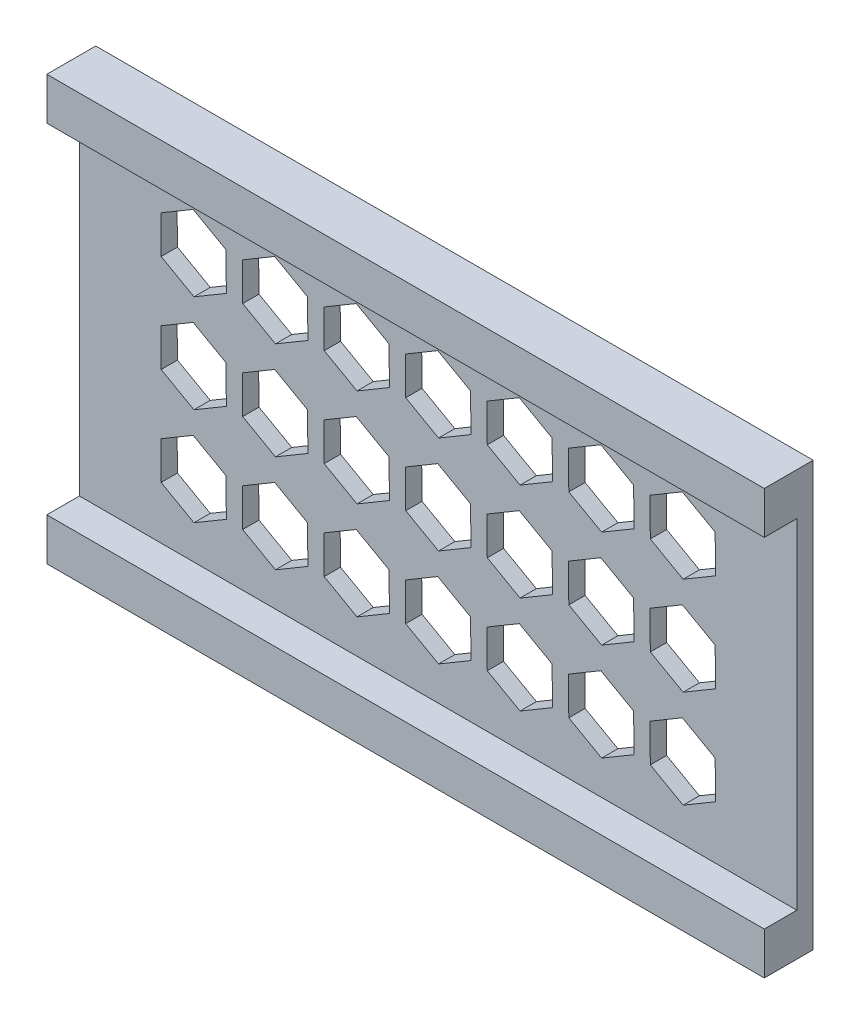
from build123d import *

# Parameters (mm, degrees)
SKETCH_3_W          = 220
SKETCH_3_H          = 130
EXTRUDE_1_DEPTH     = 5
CUT_EXTRUDE_1_DEPTH = 128.867118525
SKETCH_3_4_W        = 220
SKETCH_3_4_H        = 13
EXTRUDE_2_DEPTH     = 15


with BuildPart() as part:
    # Эскиз3 → Бобышка-Вытянуть1 (new body)
    with BuildSketch(Plane.XY):
        Rectangle(SKETCH_3_W, SKETCH_3_H)
    extrude(amount=EXTRUDE_1_DEPTH)

    # Эскиз3<3> → Вырез-Вытянуть1 (cut, through all)
    with BuildSketch(Plane.XY):
        Polygon((35.057854749, -5.672115229), (34.941123256, 5.874300106), (24.883268507, 11.546415335), (14.942145251, 5.672115229), (15.058876744, -5.874300106), (25.116731493, -11.546415335), align=None)
        Polygon((10.057854749, -5.672115229), (9.941123256, 5.874300106), (-0.116731493, 11.546415335), (-10.057854749, 5.672115229), (-9.941123256, -5.874300106), (0.116731493, -11.546415335), align=None)
        Polygon((60.057854749, -5.672115229), (59.941123256, 5.874300106), (49.883268507, 11.546415335), (39.942145251, 5.672115229), (40.058876744, -5.874300106), (50.116731493, -11.546415335), align=None)
        Polygon((85.057854749, -5.672115229), (84.941123256, 5.874300106), (74.883268507, 11.546415335), (64.942145251, 5.672115229), (65.058876744, -5.874300106), (75.116731493, -11.546415335), align=None)
        Polygon((-14.943422809, -5.672115229), (-15.060154302, 5.874300106), (-25.118009051, 11.546415335), (-35.059132307, 5.672115229), (-34.942400814, -5.874300106), (-24.884546065, -11.546415335), align=None)
        Polygon((-39.944700367, -5.672115229), (-40.06143186, 5.874300106), (-50.119286609, 11.546415335), (-60.060409866, 5.672115229), (-59.943678372, -5.874300106), (-49.885823623, -11.546415335), align=None)
        Polygon((-64.945977925, -5.672115229), (-65.062709418, 5.874300106), (-75.120564167, 11.546415335), (-85.061687424, 5.672115229), (-84.944955931, -5.874300106), (-74.887101181, -11.546415335), align=None)
        Polygon((-64.945977925, 24.327884771), (-65.062709418, 35.874300106), (-75.120564167, 41.546415335), (-85.061687424, 35.672115229), (-84.944955931, 24.125699894), (-74.887101181, 18.453584665), align=None)
        Polygon((-39.944700367, 24.327884771), (-40.06143186, 35.874300106), (-50.119286609, 41.546415335), (-60.060409866, 35.672115229), (-59.943678372, 24.125699894), (-49.885823623, 18.453584665), align=None)
        Polygon((-14.943422809, 24.327884771), (-15.060154302, 35.874300106), (-25.118009051, 41.546415335), (-35.059132307, 35.672115229), (-34.942400814, 24.125699894), (-24.884546065, 18.453584665), align=None)
        Polygon((10.057854749, 24.327884771), (9.941123256, 35.874300106), (-0.116731493, 41.546415335), (-10.057854749, 35.672115229), (-9.941123256, 24.125699894), (0.116731493, 18.453584665), align=None)
        Polygon((35.057854749, 24.327884771), (34.941123256, 35.874300106), (24.883268507, 41.546415335), (14.942145251, 35.672115229), (15.058876744, 24.125699894), (25.116731493, 18.453584665), align=None)
        Polygon((60.057854749, 24.327884771), (59.941123256, 35.874300106), (49.883268507, 41.546415335), (39.942145251, 35.672115229), (40.058876744, 24.125699894), (50.116731493, 18.453584665), align=None)
        Polygon((85.057854749, 24.327884771), (84.941123256, 35.874300106), (74.883268507, 41.546415335), (64.942145251, 35.672115229), (65.058876744, 24.125699894), (75.116731493, 18.453584665), align=None)
        Polygon((-39.944700367, -35.672115229), (-40.06143186, -24.125699894), (-50.119286609, -18.453584665), (-60.060409866, -24.327884771), (-59.943678372, -35.874300106), (-49.885823623, -41.546415335), align=None)
        Polygon((-14.943422809, -35.672115229), (-15.060154302, -24.125699894), (-25.118009051, -18.453584665), (-35.059132307, -24.327884771), (-34.942400814, -35.874300106), (-24.884546065, -41.546415335), align=None)
        Polygon((-64.945977925, -35.672115229), (-65.062709418, -24.125699894), (-75.120564167, -18.453584665), (-85.061687424, -24.327884771), (-84.944955931, -35.874300106), (-74.887101181, -41.546415335), align=None)
        Polygon((10.057854749, -35.672115229), (9.941123256, -24.125699894), (-0.116731493, -18.453584665), (-10.057854749, -24.327884771), (-9.941123256, -35.874300106), (0.116731493, -41.546415335), align=None)
        Polygon((35.057854749, -35.672115229), (34.941123256, -24.125699894), (24.883268507, -18.453584665), (14.942145251, -24.327884771), (15.058876744, -35.874300106), (25.116731493, -41.546415335), align=None)
        Polygon((60.057854749, -35.672115229), (59.941123256, -24.125699894), (49.883268507, -18.453584665), (39.942145251, -24.327884771), (40.058876744, -35.874300106), (50.116731493, -41.546415335), align=None)
        Polygon((75.116731493, -41.546415335), (85.057854749, -35.672115229), (84.941123256, -24.125699894), (74.883268507, -18.453584665), (64.942145251, -24.327884771), (65.058876744, -35.874300106), align=None)
    extrude(amount=CUT_EXTRUDE_1_DEPTH, mode=Mode.SUBTRACT)

    # Эскиз3<4> → Бобышка-Вытянуть2 (add)
    with BuildSketch(Plane.XY):
        with Locations((0, -58.5)):
            Rectangle(SKETCH_3_4_W, SKETCH_3_4_H)
        with Locations((0, 58.5)):
            Rectangle(SKETCH_3_4_W, SKETCH_3_4_H)
    extrude(amount=EXTRUDE_2_DEPTH)


solid = part.part
